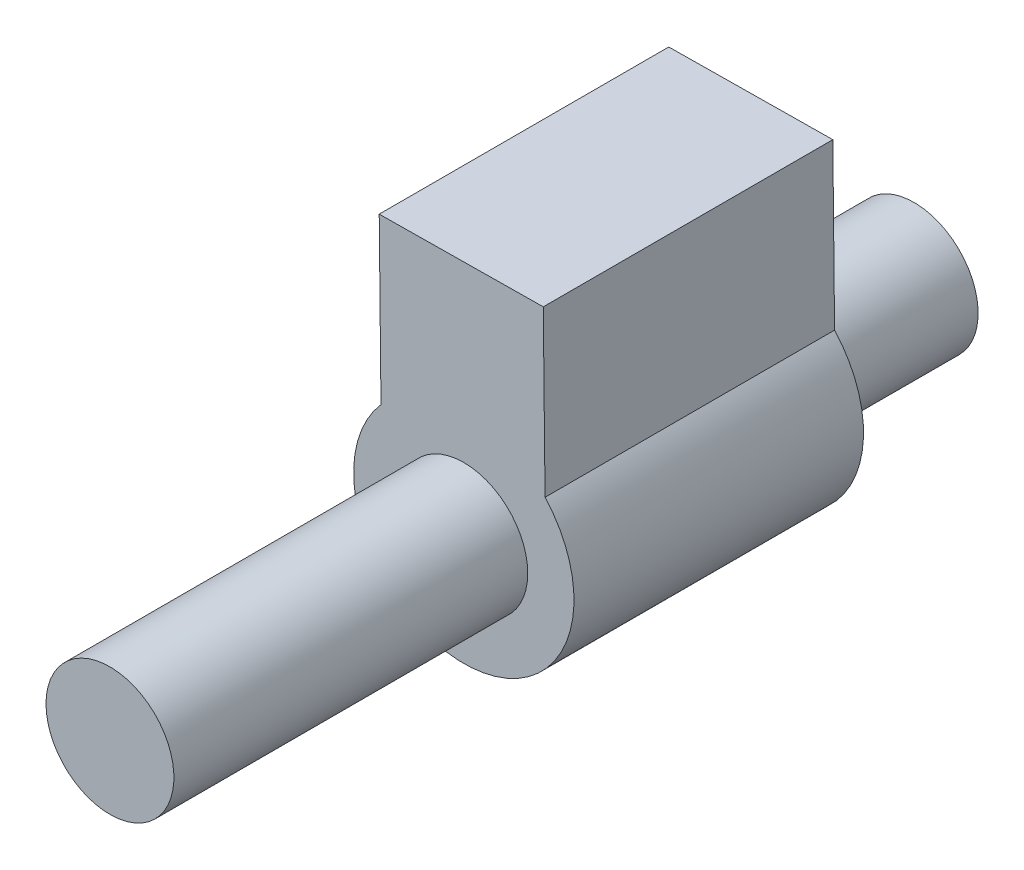
from build123d import *

# Parameters (mm, degrees)
BOSS_EXTRUDE1_DEPTH      = 18
SKETCH4_R                = 3.975
BOSS_EXTRUDE2_DEPTH      = 10
BOSS_EXTRUDE2_DEPTH_BACK = 40


with BuildPart() as part:
    # Sketch1 → Boss-Extrude1 (new body)
    with BuildSketch(Plane.XY):
        with BuildLine():
            Line((0.700840098, 16.455896919), (0.810681557, 6.255896919))
            ThreePointArc((0.810681557, 6.255896919), (5.886159138, 8.587996721), (11.010681557, 6.365738378))
            Line((11.010681557, 6.365738378), (10.900840098, 16.565738378))
            Line((10.900840098, 16.565738378), (0.700840098, 16.455896919))
        make_face()
        with BuildLine():
            ThreePointArc((11.010681557, 6.365738378), (5.886159138, 8.587996721), (0.810681557, 6.255896919))
            Line((0.810681557, 6.255896919), (11.010681557, 6.365738378))
        make_face()
        with BuildLine():
            Line((11.010681557, 6.365738378), (0.810681557, 6.255896919))
            ThreePointArc((0.810681557, 6.255896919), (3.546395485, -4.672331118), (12.809920939, 1.738393871))
            ThreePointArc((12.809920939, 1.738393871), (12.344285051, 4.220811017), (11.010681557, 6.365738378))
        make_face()
    extrude(amount=BOSS_EXTRUDE1_DEPTH)

    # Sketch4 → Boss-Extrude2 (add, two sides)
    with BuildSketch(Plane(origin=(0, 0, 0), x_dir=(-1, 0, 0), z_dir=(0, 0, -1))) as boss_extrude2_sk:
        with Locations((-5.959920939, 1.738393871)):
            Circle(SKETCH4_R)
    extrude(amount=BOSS_EXTRUDE2_DEPTH)
    extrude(boss_extrude2_sk.sketch, amount=-BOSS_EXTRUDE2_DEPTH_BACK)


solid = part.part
